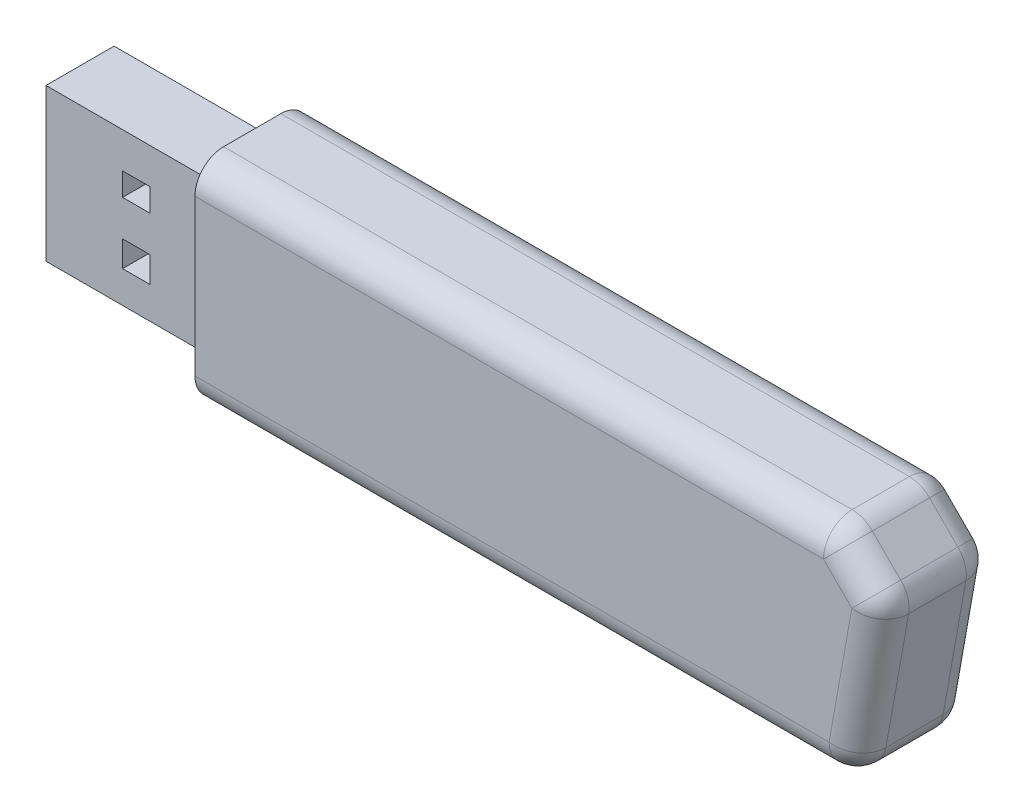
from build123d import *

# Parameters (mm, degrees)
SKETCH1_W           = 120
SKETCH1_H           = 37.194444444
BOSS_EXTRUDE4_DEPTH = 20
CUT_EXTRUDE15_DEPTH = 23
SKETCH10_W          = 11.898671916
SKETCH10_H          = 26.611218947
SKETCH10_W_2        = 10.049553983
SKETCH10_H_2        = 23.877740264
BOSS_EXTRUDE5_DEPTH = 30
SKETCH11_W          = 5.024776991
SKETCH11_H          = 23.877740264
BOSS_EXTRUDE6_DEPTH = 30
SKETCH12_W          = 4.765877192
SKETCH12_H          = 4.013370267
SKETCH12_H_2        = 4.515041551
CUT_EXTRUDE16_DEPTH = 16.868939526
FILLET2_R           = 5
SKETCH16_W          = 46.35727902
SKETCH16_H          = 19.765742142
CUT_EXTRUDE17_DEPTH = 5
FILLET3_R           = 5


with BuildPart() as part:
    # Sketch1 → Boss-Extrude4 (new body)
    with BuildSketch(Plane.XY):
        Polygon((36.833333333, 25.458333333), (36.833333333, 18.597222222), (60, 18.597222222), (60, -18.597222222), (68.25, -18.597222222), (72.583333333, 25.458333333), align=None)
        Rectangle(SKETCH1_W, SKETCH1_H)
    extrude(amount=BOSS_EXTRUDE4_DEPTH)

    # Sketch6 → Cut-Extrude15 (cut)
    with BuildSketch(Plane.XY.offset(20)):
        Polygon((51.910176302, 18.597222222), (36.833333333, 18.597222222), (36.833333333, 25.458333333), (72.583333333, 25.458333333), (68.25, -18.597222222), (55.010463364, -18.597222222), (60.177305366, 10.330093158), align=None)
    extrude(amount=-CUT_EXTRUDE15_DEPTH, mode=Mode.SUBTRACT)

    # Sketch10 → Boss-Extrude5 (add)
    with BuildSketch(Plane.ZY.offset(60)):
        with Locations((10.080396432, 0.080396432)):
            Rectangle(SKETCH10_W, SKETCH10_H)
        with Locations((10.120594648, 0.080396432)):
            Rectangle(SKETCH10_W_2, SKETCH10_H_2, mode=Mode.SUBTRACT)
    extrude(amount=BOSS_EXTRUDE5_DEPTH)

    # Sketch11 → Boss-Extrude6 (add)
    with BuildSketch(Plane.ZY.offset(60)):
        with Locations((12.632983144, 0.080396432)):
            Rectangle(SKETCH11_W, SKETCH11_H)
    extrude(amount=BOSS_EXTRUDE6_DEPTH)

    # Sketch12 → Cut-Extrude16 (cut, through all)
    with BuildSketch(Plane(origin=(0, 0, 4.131060474), x_dir=(-1, 0, 0), z_dir=(0, 0, -1))):
        with Locations((74.233976577, 5.142130655)):
            Rectangle(SKETCH12_W, SKETCH12_H)
        with Locations((74.233976577, -5.392966297)):
            Rectangle(SKETCH12_W, SKETCH12_H_2)
    extrude(amount=-CUT_EXTRUDE16_DEPTH, mode=Mode.SUBTRACT)

    # Fillet2
    fillet2_edges = [part.edges().sort_by_distance(p)[0] for p in [
        (-2.494768318, -18.597222222, 0),
        (56.043740834, 14.46365769, 0),
        (57.593884365, -4.133564532, 0),
        (-4.044911849, 18.597222222, 20),
        (-2.494768318, -18.597222222, 20),
        (55.010463364, -18.597222222, 10),
        (60.177305366, 10.330093158, 10),
        (51.910176302, 18.597222222, 10),
        (56.043740834, 14.46365769, 20),
        (57.593884365, -4.133564532, 20),
        (-4.044911849, 18.597222222, 0),
    ]]
    fillet(fillet2_edges, radius=FILLET2_R)

    # Sketch16 → Cut-Extrude17 (cut)
    with BuildSketch(Plane(origin=(0, 0, 0), x_dir=(-1, 0, 0), z_dir=(0, 0, -1))):
        Rectangle(SKETCH16_W, SKETCH16_H)
    extrude(amount=-CUT_EXTRUDE17_DEPTH, mode=Mode.SUBTRACT)

    # Fillet3
    fillet3_edges = [part.edges().sort_by_distance(p)[0] for p in [
        (23.17863951, -9.882871071, 2.5),
        (23.17863951, 9.882871071, 2.5),
        (-23.17863951, 9.882871071, 2.5),
        (-23.17863951, -9.882871071, 2.5),
    ]]
    fillet(fillet3_edges, radius=FILLET3_R)


solid = part.part
